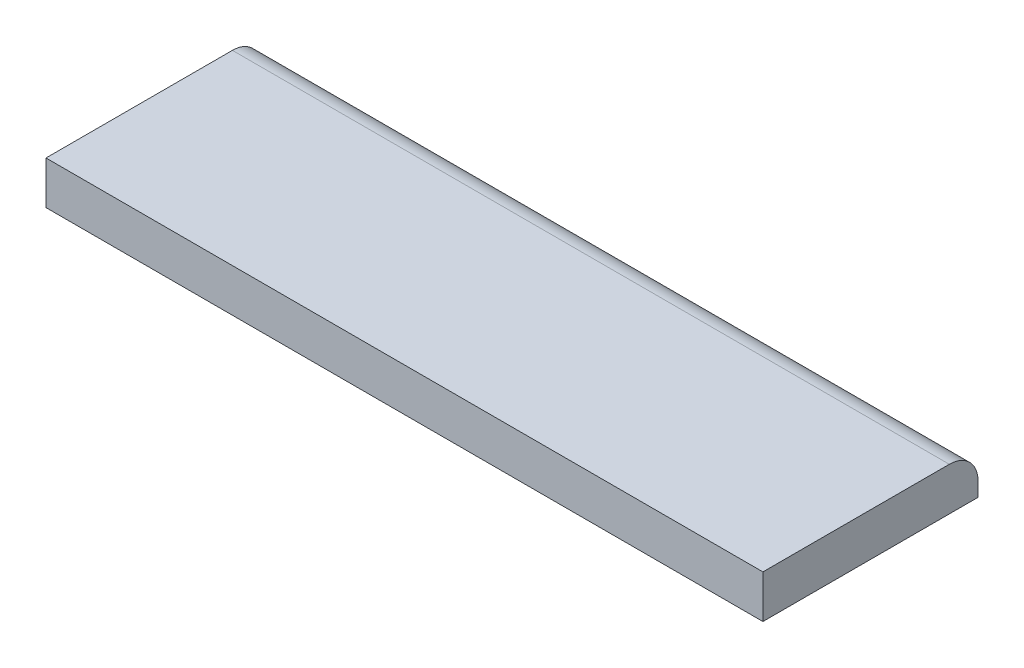
from build123d import *

# Parameters (mm, degrees)
SKETCH1_W           = 50
SKETCH1_H           = 15
BOSS_EXTRUDE1_DEPTH = 3
FILLET2_R           = 2


with BuildPart() as part:
    # Sketch1 → Boss-Extrude1 (new body)
    with BuildSketch(Plane(origin=(0, 0, 0), x_dir=(1, 0, 0), z_dir=(0, 1, 0))):
        with Locations((25, 7.5)):
            Rectangle(SKETCH1_W, SKETCH1_H)
    extrude(amount=BOSS_EXTRUDE1_DEPTH)

    # Fillet2
    fillet2_edges = [part.edges().sort_by_distance(p)[0] for p in [
        (25, 3, -15),
    ]]
    fillet(fillet2_edges, radius=FILLET2_R)


solid = part.part
